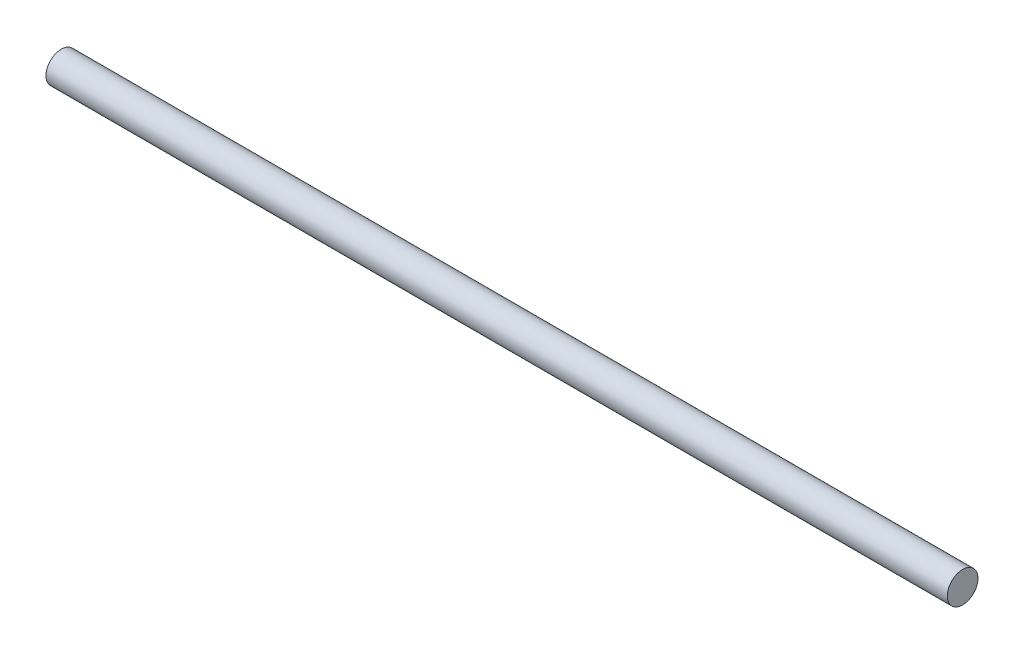
from build123d import *

# Parameters (mm, degrees)
SKETCH1_R           = 6
BOSS_EXTRUDE1_DEPTH = 175.825


with BuildPart() as part:
    # Sketch1 → Boss-Extrude1 (new body, symmetric)
    with BuildSketch(Plane(origin=(0, 0, 0), x_dir=(0, 0, -1), z_dir=(1, 0, 0))):
        Circle(SKETCH1_R)
    extrude(amount=BOSS_EXTRUDE1_DEPTH, both=True)


solid = part.part
